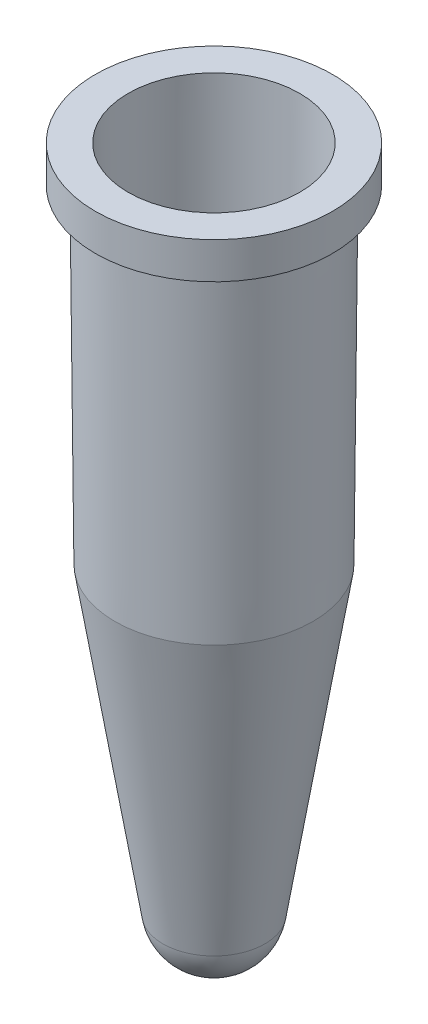
from build123d import *

# Parameters (mm, degrees)
BOSS_EXTRUDE4_DEPTH = 2.000034
SCALE1_SCALE        = 0.510872955


with BuildPart() as part:
    # Sketch1 → Revolve25 (revolve)
    with BuildSketch(Plane.XY):
        with BuildLine():
            Line((-4.682614804, -1.992146118), (-4.7, 0))
            Line((-4.7, 0), (-6.5, 0))
            Line((-6.5, 0), (-6.5, -2))
            Line((-6.5, -2), (-5.582580535, -2))
            Line((-5.582580535, -2), (-5.425496915, -20))
            Line((-5.425496915, -20), (-2.794168337, -36.613554791))
            ThreePointArc((-2.794168337, -36.613554791), (-1.837287228, -38.322188957), (0, -39))
            Line((0, -39), (0, -38.1))
            ThreePointArc((0, -38.1), (-1.252783984, -37.637823588), (-1.905248831, -36.472763773))
            Line((-1.905248831, -36.472763773), (-4.526114828, -19.925267112))
            Line((-4.526114828, -19.925267112), (-4.682614804, -1.992146118))
        make_face()
    revolve(axis=Axis((0, 0, 0), (0, -1, 0)))


with BuildPart() as body_2:
    # Sketch1_10 → Revolve31 (revolve)
    with BuildSketch(Plane.XY):
        Polygon((22, 2.999966443), (22, 1.999966443), (26, 1.999966443), (26, -2.000033557), (28.5, -2.000033557), (28.5, 0), (26.7, 0), (26.569018636, 2.999966443), align=None)
    revolve(axis=Axis((22, 17.95552364, 0), (0, -1, 0)))

    # Sketch2 → Boss-Extrude4 (add)
    with BuildSketch(Plane(origin=(0, -2.000033557, 0), x_dir=(-1, 0, 0), z_dir=(0, -1, 0))):
        with BuildLine():
            Line((-22, 4), (-22, 6.5))
            add(Edge.make_bspline(
                [(-22, 6.5), (-30.5, 6.5), (-30.5, 0), (-30.5, -6.5), (-22, -6.5)],
                knots=[1.570796327, 1.570796327, 1.570796327, 3.141592654, 3.141592654, 4.71238898, 4.71238898, 4.71238898], degree=2, weights=[1, 0.707106781, 1, 0.707106781, 1]))
            Line((-22, -6.5), (-22, -4))
            ThreePointArc((-22, -4), (-26, 0), (-22, 4))
        make_face()
    extrude(amount=-BOSS_EXTRUDE4_DEPTH)


with BuildPart() as part_1:
    # Scale1: scaled about (0, -15.998689943, 0)
    add(part.part.scale(SCALE1_SCALE).moved(Location((0, -7.825391937, 0))))


solid = part_1.part
